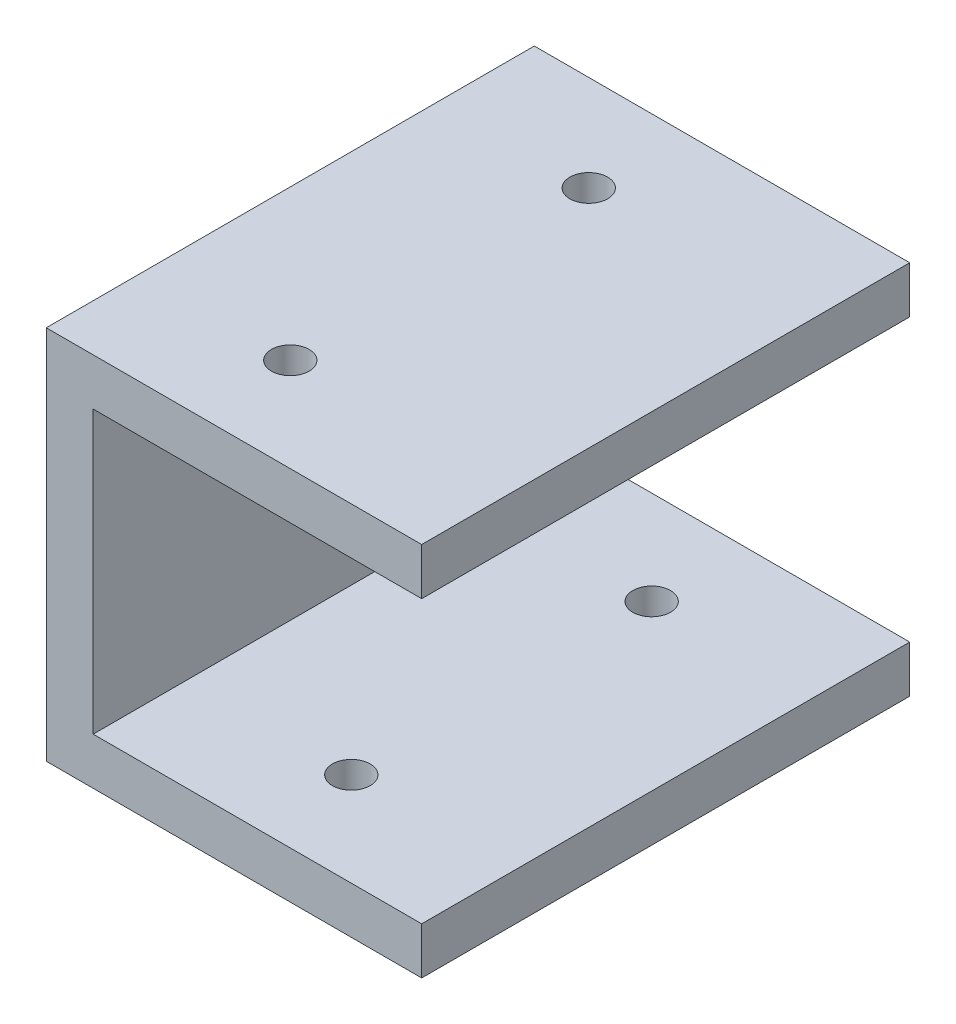
from build123d import *

# Parameters (mm, degrees)
BOSS_EXTRUDE1_DEPTH         = 66.04
F_1_4_20_TAPPED_HOLE1_D     = 5.1054
F_1_4_20_TAPPED_HOLE1_DEPTH = 6.35
F_1_4_20_TAPPED_HOLE2_D     = 5.1054
F_1_4_20_TAPPED_HOLE2_DEPTH = 6.35


with BuildPart() as part:
    # Sketch1 → Boss-Extrude1 (new body)
    with BuildSketch(Plane.XY):
        Polygon((-18.735809365, -25.616936059), (25.714190635, -25.616936059), (25.714190635, -19.266936059), (-25.085809365, -19.266936059), (-25.085809365, -70.066936059), (25.714190635, -70.066936059), (25.714190635, -63.716936059), (-18.735809365, -63.716936059), align=None)
    extrude(amount=-BOSS_EXTRUDE1_DEPTH)

    # 1/4-20 Tapped Hole1
    with Locations(Plane(origin=(0, -19.266936059, 0), x_dir=(1, 0, 0), z_dir=(0, 1, 0))):
        with Locations((-4.765809365, 53.086), (-4.765809365, 12.7)):
            Hole(F_1_4_20_TAPPED_HOLE1_D / 2, depth=F_1_4_20_TAPPED_HOLE1_DEPTH)

    # 1/4-20 Tapped Hole2
    with Locations(Plane(origin=(0, -70.066936059, 0), x_dir=(-1, 0, 0), z_dir=(0, -1, 0))):
        with Locations((-3.489190635, 12.7), (-3.489190635, 53.34)):
            Hole(F_1_4_20_TAPPED_HOLE2_D / 2, depth=F_1_4_20_TAPPED_HOLE2_DEPTH)


solid = part.part
